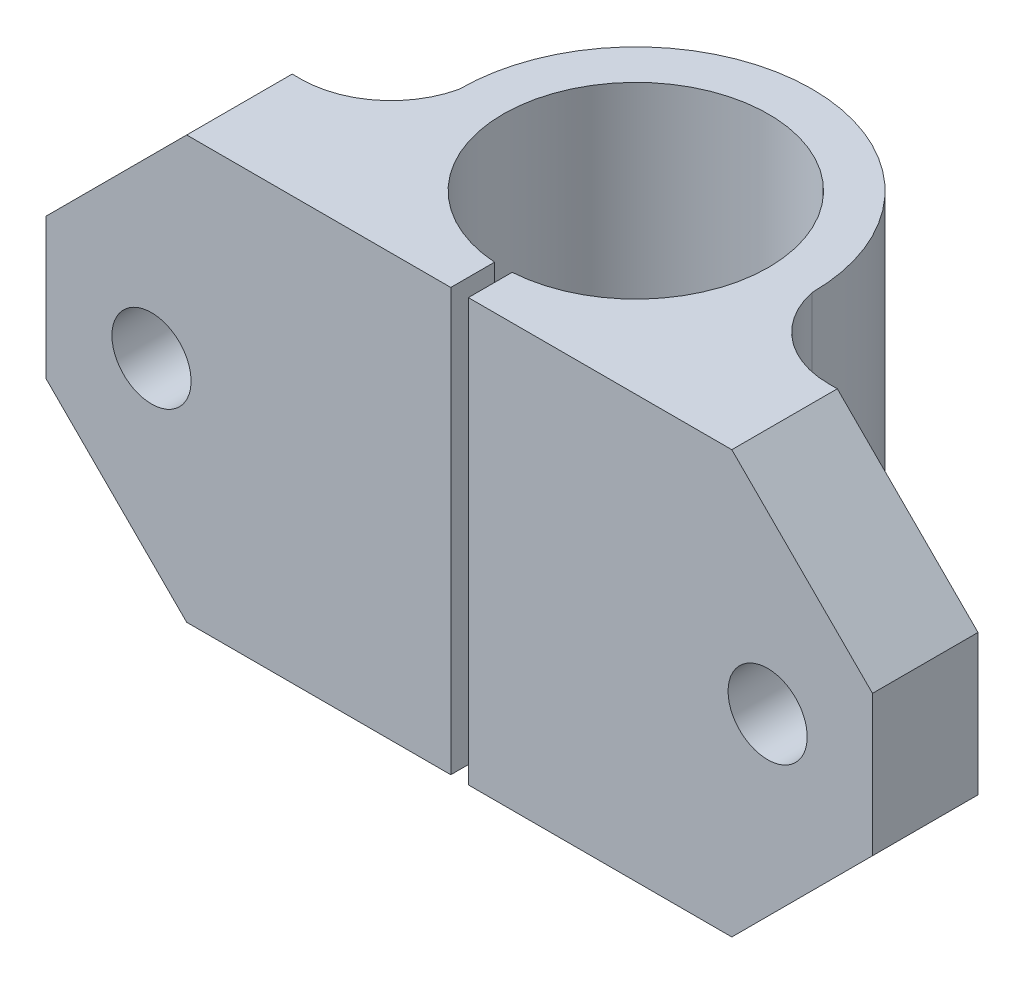
from build123d import *

# Parameters (mm, degrees)
BOSS_EXTRUDE1_DEPTH            = 24
CUT_EXTRUDE1_DEPTH             = 25
SKETCH3_W                      = 7.55
SKETCH3_H                      = 24
F_4_5_4_5_DIAMETER_HOLE1_D     = 4.5
F_4_5_4_5_DIAMETER_HOLE1_DEPTH = 6
CHAMFER1_SIZE                  = 8


with BuildPart() as part:
    # Sketch1 → Boss-Extrude1 (new body)
    with BuildSketch(Plane(origin=(0, 24, 0), x_dir=(1, 0, 0), z_dir=(0, 1, 0))):
        with BuildLine():
            Line((0, 0), (47, 0))
            Line((47, 0), (47, 6))
            Line((47, 6), (38.5, 6))
            ThreePointArc((38.5, 6), (35.307693119, 7.131854655), (33.541354656, 10.021831577))
            ThreePointArc((33.541354656, 10.021831577), (23.505747016, 20.045434485), (13.49594739, 9.996059012))
            ThreePointArc((13.49594739, 9.996059012), (11.698748894, 7.121907302), (8.5, 6))
            Line((8.5, 6), (0, 6))
            Line((0, 6), (0, 0))
        make_face()
    extrude(amount=-BOSS_EXTRUDE1_DEPTH)

    # Sketch2 → Cut-Extrude1 (cut, through all)
    with BuildSketch(Plane.XZ):
        with BuildLine():
            Line((24.018633311, 0), (23.018633311, 0))
            Line((23.018633311, 0), (23.018633311, -2.489295869))
            ThreePointArc((23.018633311, -2.489295869), (23.518633311, -2.472721384), (24.018633311, -2.489295869))
            Line((24.018633311, -2.489295869), (24.018633311, 0))
        make_face()
    extrude(amount=-CUT_EXTRUDE1_DEPTH, mode=Mode.SUBTRACT)

    # Sketch3 → Cut-Revolve1 (revolve, cut)
    with BuildSketch(Plane(origin=(0, 0, -10.022721384), x_dir=(-1, 0, 0), z_dir=(0, 0, -1))):
        with Locations((-27.293633311, 12)):
            Rectangle(SKETCH3_W, SKETCH3_H)
    revolve(axis=Axis((23.518633311, 0, -10.022721384), (0, 1, 0)), mode=Mode.SUBTRACT)

    # Ø4.5 (4.5) Diameter Hole1
    with Locations(Plane(origin=(0, 0, -6), x_dir=(-1, 0, 0), z_dir=(0, 0, -1))):
        with Locations((-41.037266621, 12), (-6, 12)):
            Hole(F_4_5_4_5_DIAMETER_HOLE1_D / 2, depth=F_4_5_4_5_DIAMETER_HOLE1_DEPTH)

    # Chamfer1
    chamfer1_edges = [part.edges().sort_by_distance(p)[0] for p in [
        (47, 0, -3),
        (0, 24, -3),
        (0, 0, -3),
        (47, 24, -3),
    ]]
    chamfer(chamfer1_edges, length=CHAMFER1_SIZE)


solid = part.part
